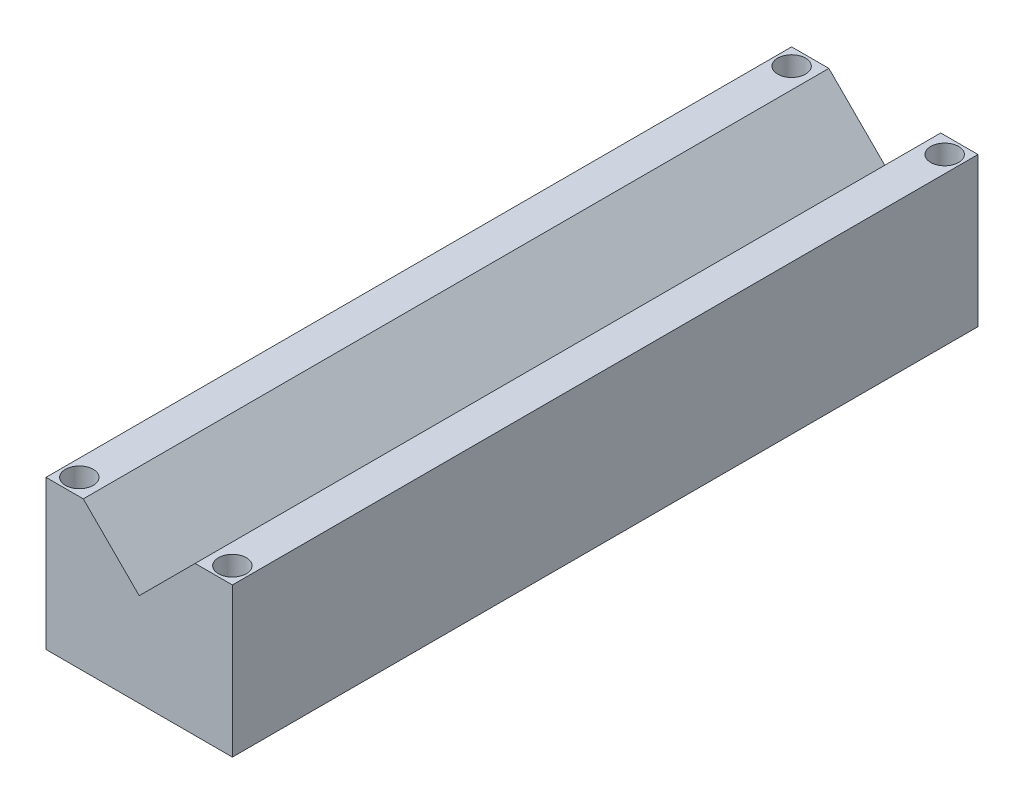
from build123d import *

# Parameters (mm, degrees)
CROQUIS2_W              = 63.5
CROQUIS2_H              = 50.8
SALIENTE_EXTRUIR1_DEPTH = 254
CROQUIS5_R              = 3.175
CORTAR_EXTRUIR3_DEPTH   = 50.8
CROQUIS10_R             = 4.75
CORTAR_EXTRUIR5_DEPTH   = 8
CORTAR_EXTRUIR6_DEPTH   = 254
CROQUIS12_R             = 4.75
CORTAR_EXTRUIR7_DEPTH   = 8


with BuildPart() as part:
    # Croquis2 → Saliente-Extruir1 (new body)
    with BuildSketch(Plane.XY):
        with Locations((31.75, 25.4)):
            Rectangle(CROQUIS2_W, CROQUIS2_H)
    extrude(amount=-SALIENTE_EXTRUIR1_DEPTH)

    # Croquis5 → Cortar-Extruir3 (cut)
    with BuildSketch(Plane(origin=(0, 50.8, 0), x_dir=(1, 0, 0), z_dir=(0, 1, 0))):
        with Locations((57.82, 5.675)):
            Circle(CROQUIS5_R)
        with Locations((5.68, 5.675)):
            Circle(CROQUIS5_R)
        with Locations((5.68, 248.325)):
            Circle(CROQUIS5_R)
        with Locations((57.82, 248.325)):
            Circle(CROQUIS5_R)
    extrude(amount=-CORTAR_EXTRUIR3_DEPTH, mode=Mode.SUBTRACT)

    # Croquis10 → Cortar-Extruir5 (cut)
    with BuildSketch(Plane(origin=(0, 50.8, 0), x_dir=(1, 0, 0), z_dir=(0, 1, 0))):
        with Locations((57.82, 5.675)):
            Circle(CROQUIS10_R)
        with Locations((5.68, 5.675)):
            Circle(CROQUIS10_R)
    extrude(amount=-CORTAR_EXTRUIR5_DEPTH, mode=Mode.SUBTRACT)

    # Croquis11 → Cortar-Extruir6 (cut)
    with BuildSketch(Plane.XY):
        Polygon((31.75, 31.75), (50.8, 50.8), (12.7, 50.8), align=None)
    extrude(amount=-CORTAR_EXTRUIR6_DEPTH, mode=Mode.SUBTRACT)

    # Croquis12 → Cortar-Extruir7 (cut)
    with BuildSketch(Plane(origin=(0, 50.8, 0), x_dir=(1, 0, 0), z_dir=(0, 1, 0))):
        with Locations((57.82, 248.325)):
            Circle(CROQUIS12_R)
        with Locations((5.68, 248.325)):
            Circle(CROQUIS12_R)
    extrude(amount=-CORTAR_EXTRUIR7_DEPTH, mode=Mode.SUBTRACT)


solid = part.part
